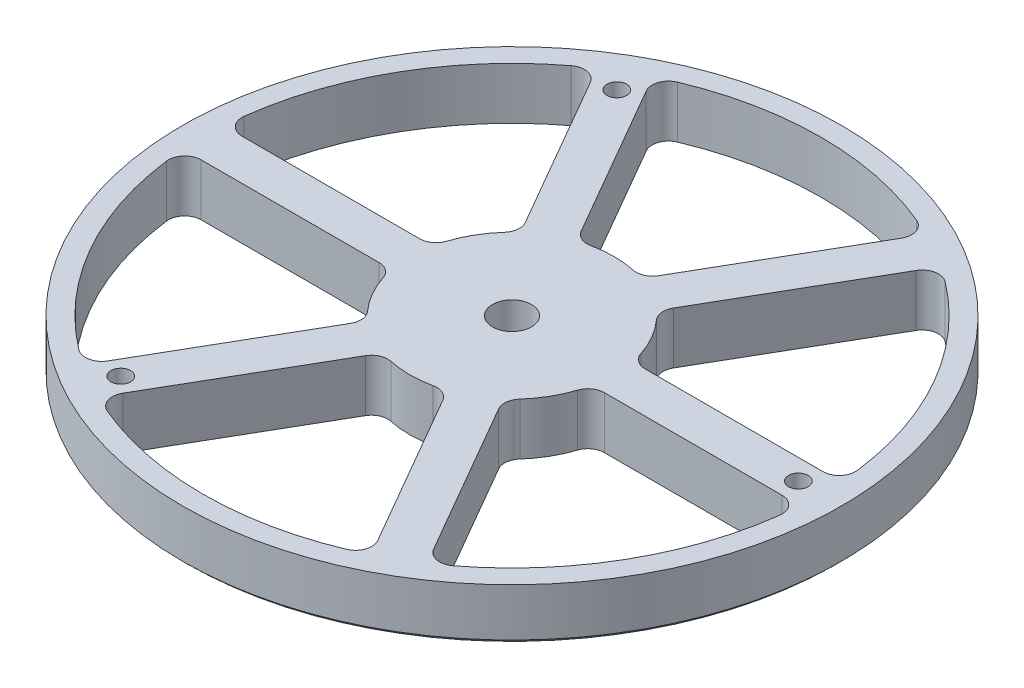
from build123d import *

# Parameters (mm, degrees)
F_12_0_189_DIAMETER_HOLE1_D  = 4.8006
CIRPATTERN3_COUNT            = 3
CUT_EXTRUDE1_DEPTH           = 115.6206569515286
FILLET1_R                    = 4
CIRPATTERN4_COUNT            = 6
FILLET1_OF_CIRPATTERN4_R     = 4
CHAMFER2_SIZE                = 1
F_3_8_0_375_DIAMETER_HOLE1_D = 9.525


with BuildPart() as part:
    # Sketch2 → Revolve1 (revolve)
    with BuildSketch(Plane(origin=(0, 0, 0), x_dir=(0, 0, -1), z_dir=(1, 0, 0)), mode=Mode.PRIVATE) as revolve1_sk:
        Polygon((0, 0), (-80.55, -9.86e-15), (-80.55, 12.699999999999989), (0, 12.699999999999989), align=None)
    revolve(revolve1_sk.sketch.rotate(Axis((0, -0.6350000000000106, 0), (0, 1, 0)), 180), axis=Axis((0, -0.6350000000000106, 0), (0, 1, 0)))

    # #12 (0.189) Diameter Hole1 (through all)
    with Locations(Plane(origin=(0, 12.699999999999989, 0), x_dir=(1, 0, 0), z_dir=(0, 1, 0))):
        with Locations((-35, 60.621778265)):
            f_12_0_189_diameter_hole1 = Hole(F_12_0_189_DIAMETER_HOLE1_D / 2)

    # CirPattern3: #12 (0.189) Diameter Hole1 ×3 about axis
    cirpattern3_axis = Axis((2.7e-16, 0, 4.47e-15), (0, 1, 0))
    for i in range(1, CIRPATTERN3_COUNT):
        add(f_12_0_189_diameter_hole1.rotate(cirpattern3_axis, i * 360 / CIRPATTERN3_COUNT), mode=Mode.SUBTRACT)

    # Sketch8 → Cut-Extrude1 (cut, through all)
    with BuildSketch(Plane(origin=(0, 12.699999999999989, 0), x_dir=(1, 0, 0), z_dir=(0, 1, 0))):
        with BuildLine():
            Line((-7.91732169499373, 23.713203435596423), (-33.36205552600357, 67.784775215972))
            ThreePointArc((-33.36205552600357, 67.784775215972), (4.63e-15, 75.54999999999998), (33.36205552600357, 67.784775215972))
            Line((33.36205552600357, 67.784775215972), (7.917321694993729, 23.713203435596423))
            ThreePointArc((7.917321694993729, 23.713203435596423), (1.53e-15, 25.000000000000007), (-7.91732169499373, 23.713203435596423))
        make_face()
    cut_extrude1 = extrude(amount=-CUT_EXTRUDE1_DEPTH, mode=Mode.SUBTRACT)

    # Fillet1
    fillet1_edges = [part.edges().sort_by_distance(p)[0] for p in [
        (7.9173216949937295, 6.349999999999994, -23.713203435596427),
        (-7.9173216949937295, 6.349999999999994, -23.713203435596427),
        (-33.36205552600357, 6.349999999999994, -67.78477521597199),
        (33.36205552600358, 6.349999999999994, -67.78477521597199),
    ]]
    fillet(fillet1_edges, radius=FILLET1_R)

    # CirPattern4: Cut-Extrude1 ×6 about axis
    cirpattern4_axis = Axis((-3.068e-14, 0, 1.3e-16), (0, 1, 0))
    for i in range(1, CIRPATTERN4_COUNT):
        add(cut_extrude1.rotate(cirpattern4_axis, i * 360 / CIRPATTERN4_COUNT), mode=Mode.SUBTRACT)

    # Fillet1 of CirPattern4
    fillet1_of_cirpattern4_edges = [part.edges().sort_by_distance(p)[0] for p in [
        (-16.57757573283808, 6.349999999999994, -18.71320343559648),
        (-24.494897427831813, 6.349999999999994, -5.000000000000001),
        (-75.38436508985136, 6.349999999999994, -4.999999999999924),
        (-42.02230956384777, 6.349999999999994, -62.78477521597215),
        (-24.49489742783184, 6.349999999999994, 4.99999999999994),
        (-16.577575732838117, 6.349999999999994, 18.713203435596423),
        (-42.02230956384782, 6.349999999999994, 62.78477521597206),
        (-75.38436508985139, 6.349999999999994, 4.999999999999838),
        (-7.9173216949937935, 6.349999999999994, 23.713203435596427),
        (7.917321694993666, 6.349999999999994, 23.713203435596427),
        (33.3620555260035, 6.349999999999994, 67.78477521597199),
        (-33.36205552600365, 6.349999999999994, 67.78477521597199),
        (16.57757573283801, 6.349999999999994, 18.71320343559649),
        (24.49489742783175, 6.349999999999994, 5.0000000000000115),
        (75.3843650898513, 6.349999999999994, 4.999999999999952),
        (42.022309563847685, 6.349999999999994, 62.78477521597216),
        (24.494897427831784, 6.349999999999994, -4.999999999999948),
        (16.577575732838053, 6.349999999999994, -18.71320343559643),
        (42.02230956384774, 6.349999999999994, -62.784775215972076),
        (75.38436508985133, 6.349999999999994, -4.999999999999863),
    ]]
    fillet(fillet1_of_cirpattern4_edges, radius=FILLET1_OF_CIRPATTERN4_R)

    # Chamfer2
    chamfer2_edges = [part.edges().sort_by_distance(p)[0] for p in [
        (-1.973e-14, -9.88e-15, 80.55),
    ]]
    chamfer(chamfer2_edges, length=CHAMFER2_SIZE)

    # 3/8 (0.375) Diameter Hole1 (through all)
    with Locations(Plane(origin=(0, 0, 0), x_dir=(-1, 0, 0), z_dir=(0, -1, 0))):
        with Locations((0, 0)):
            Hole(F_3_8_0_375_DIAMETER_HOLE1_D / 2)


solid = part.part
